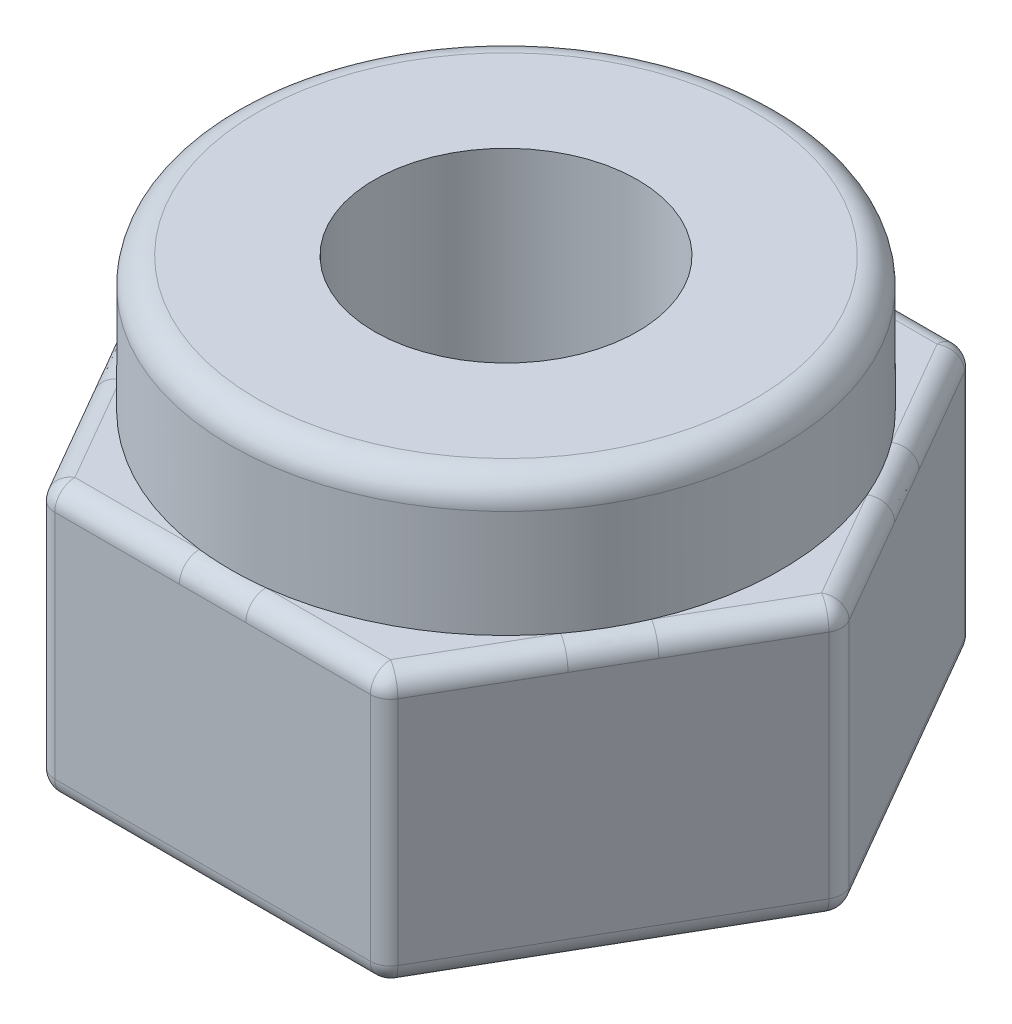
from build123d import *

# Parameters (mm, degrees)
EXTRUDE1_DEPTH = 5.1308
SKETCH2_W      = 5.207
SKETCH2_H      = 2.54
HOLEWZD1_D     = 4.97586
HOLEWZD1_DEPTH = 7.6708
FILLET1_R      = 0.381
FILLET2_R      = 0.508


with BuildPart() as part:
    # Sketch1 → Extrude1 (new body)
    with BuildSketch(Plane(origin=(0, -2.54, 0), x_dir=(-1, 0, 0), z_dir=(0, 1, 0))):
        Polygon((3.204236259, 5.5499), (-3.204236259, 5.5499), (-6.408472518, 0), (-3.204236259, -5.5499), (3.204236259, -5.5499), (6.408472518, 0), align=None)
    extrude(amount=-EXTRUDE1_DEPTH)

    # Sketch2 → Revolve1 (revolve)
    with BuildSketch(Plane(origin=(0, 0, 0), x_dir=(-1, 0, 0), z_dir=(0, 0, -1))):
        with Locations((-2.6035, -1.27)):
            Rectangle(SKETCH2_W, SKETCH2_H)
    revolve(axis=Axis((0, -2.54, 0), (0, 1, 0)))

    # HoleWzd1
    with Locations(Plane(origin=(0, 0, 0), x_dir=(-1, 0, 0), z_dir=(0, 1, 0))):
        with Locations((0, 0)):
            Hole(HOLEWZD1_D / 2, depth=HOLEWZD1_DEPTH)

    # Fillet1
    fillet1_edges = [part.edges().sort_by_distance(p)[0] for p in [
        (4.806354388, -7.6708, 2.77495),
        (-6.408472518, -5.1054, 0),
        (-3.204236259, -5.1054, -5.5499),
        (3.204236259, -5.1054, -5.5499),
        (6.408472518, -5.1054, 0),
        (3.204236259, -5.1054, 5.5499),
        (-3.204236259, -5.1054, 5.5499),
        (4.806354388, -7.6708, -2.77495),
        (0, -7.6708, -5.5499),
        (-4.806354388, -7.6708, -2.77495),
        (-4.806354388, -7.6708, 2.77495),
        (-4.806354388, -2.54, -2.77495),
        (0, -2.54, -5.5499),
        (4.806354388, -2.54, -2.77495),
        (0, -7.6708, 5.5499),
        (4.806354388, -2.54, 2.77495),
        (0, -2.54, 5.5499),
        (-4.806354388, -2.54, 2.77495),
    ]]
    fillet(fillet1_edges, radius=FILLET1_R)

    # Fillet2
    fillet2_edges = [part.edges().sort_by_distance(p)[0] for p in [
        (-5.207, 0, 0),
    ]]
    fillet(fillet2_edges, radius=FILLET2_R)


solid = part.part
